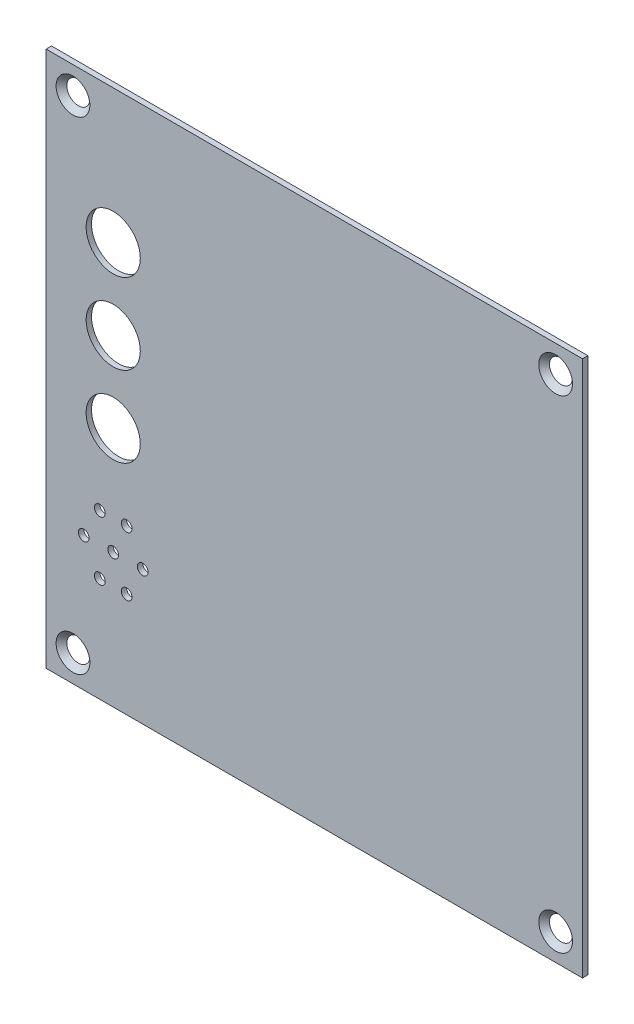
from build123d import *

# Parameters (mm, degrees)
ESQUISSE1_W                                 = 100
ESQUISSE1_H                                 = 100
BOSS_EXTRU_1_DEPTH                          = 1
FRAISAGE_POUR_VIS_T_TE_FRAIS_E_M31_AT_COUNT = 2
FRAISAGE_POUR_VIS_T_TE_FRAIS_E_M31_AT_PITCH = 90
FRAISAGE_POUR_VIS_T_TE_FRAIS_E_M31_2_COUNT  = 2
FRAISAGE_POUR_VIS_T_TE_FRAIS_E_M31_2_PITCH  = 127.279220614
FRAISAGE_POUR_VIS_T_TE_FRAIS_E_M31_3_COUNT  = 2
FRAISAGE_POUR_VIS_T_TE_FRAIS_E_M31_3_PITCH  = 90
ESQUISSE4_R                                 = 5.05
ESQUISSE4_R_2                               = 1
ENL_V_MAT_EXTRU_1_DEPTH                     = 2


with BuildPart() as part:
    # Esquisse1 → Boss.-Extru.1 (new body)
    with BuildSketch(Plane.XY):
        with Locations((50, 50)):
            Rectangle(ESQUISSE1_W, ESQUISSE1_H)
    extrude(amount=BOSS_EXTRU_1_DEPTH)

    # Esquisse3 → Fraisage pour vis à tête fraisée M31 (revolve, cut)
    with BuildSketch(Plane(origin=(5, 95, 1), x_dir=(0, -1, 0), z_dir=(1, 0, 0))):
        Polygon((0, 0), (0, 1), (1.8, 1), (1.8, 1.35), (3.15, 0), align=None)
    fraisage_pour_vis_t_te_frais_e_m31 = revolve(axis=Axis((5, 95, 7.35), (0, 0, -1)), mode=Mode.SUBTRACT)

    # Fraisage pour vis à tête fraisée M31 at: Fraisage pour vis à tête fraisée M31 ×2
    with Locations(*[(i * FRAISAGE_POUR_VIS_T_TE_FRAIS_E_M31_AT_PITCH, 0, 0) for i in range(1, FRAISAGE_POUR_VIS_T_TE_FRAIS_E_M31_AT_COUNT)]):
        add(fraisage_pour_vis_t_te_frais_e_m31, mode=Mode.SUBTRACT)

    # Fraisage pour vis _ t_te frais_e M31 2: Fraisage pour vis à tête fraisée M31 ×2
    with Locations(*[Vector(0.707106781, -0.707106781, 0) * (i * FRAISAGE_POUR_VIS_T_TE_FRAIS_E_M31_2_PITCH) for i in range(1, FRAISAGE_POUR_VIS_T_TE_FRAIS_E_M31_2_COUNT)]):
        add(fraisage_pour_vis_t_te_frais_e_m31, mode=Mode.SUBTRACT)

    # Fraisage pour vis _ t_te frais_e M31 3: Fraisage pour vis à tête fraisée M31 ×2
    with Locations(*[(0, -i * FRAISAGE_POUR_VIS_T_TE_FRAIS_E_M31_3_PITCH, 0) for i in range(1, FRAISAGE_POUR_VIS_T_TE_FRAIS_E_M31_3_COUNT)]):
        add(fraisage_pour_vis_t_te_frais_e_m31, mode=Mode.SUBTRACT)

    # Esquisse4 → Enlèv. mat.-Extru.1 (cut, through all)
    with BuildSketch(Plane.XY.offset(1)):
        with Locations((12.5, 75)):
            Circle(ESQUISSE4_R)
        with Locations((12.5, 25)):
            Circle(ESQUISSE4_R_2)
        with Locations((10, 19.5)):
            Circle(ESQUISSE4_R_2)
        with Locations((7, 25)):
            Circle(ESQUISSE4_R_2)
        with Locations((18, 25)):
            Circle(ESQUISSE4_R_2)
        with Locations((10, 30.5)):
            Circle(ESQUISSE4_R_2)
        with Locations((15, 30.5)):
            Circle(ESQUISSE4_R_2)
        with Locations((15, 19.5)):
            Circle(ESQUISSE4_R_2)
        with Locations((12.5, 60)):
            Circle(ESQUISSE4_R)
        with Locations((12.5, 45)):
            Circle(ESQUISSE4_R)
    extrude(amount=-ENL_V_MAT_EXTRU_1_DEPTH, mode=Mode.SUBTRACT)


solid = part.part
